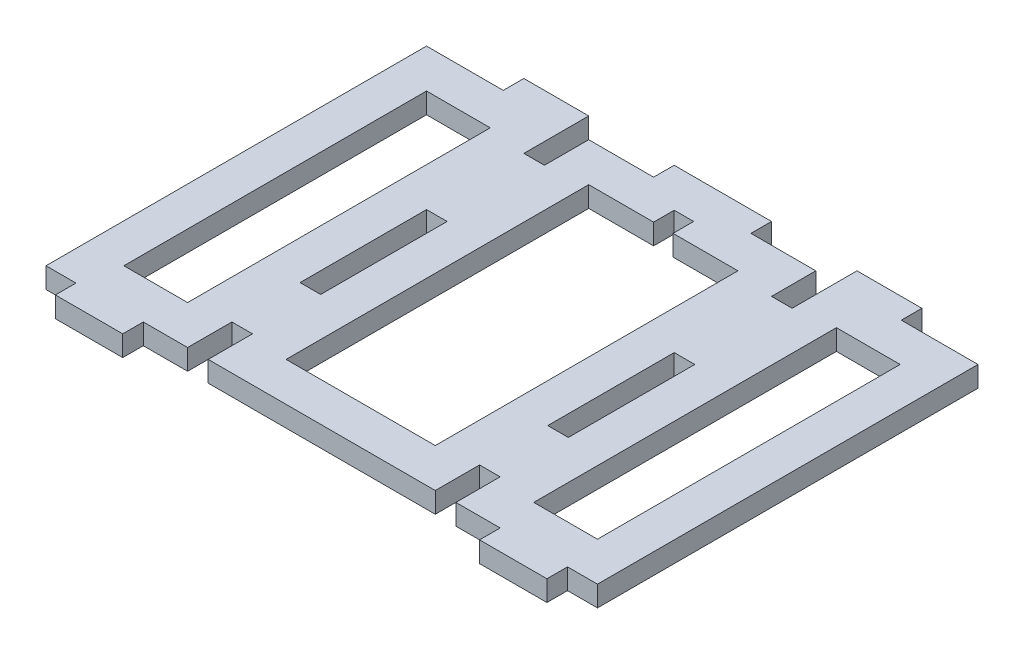
from build123d import *

# Parameters (mm, degrees)
SKETCH1_W           = 85
SKETCH1_H           = 65
BOSS_EXTRUDE1_DEPTH = 3.175
SKETCH2_W           = 3.175
SKETCH2_H           = 6.825
SKETCH2_H_2         = 3.175
SKETCH2_W_2         = 6.825
SKETCH2_W_3         = 4.619
SKETCH2_W_4         = 35
SKETCH2_H_3         = 19.492
SKETCH2_W_5         = 11.825
SKETCH2_W_6         = 10
CUT_EXTRUDE1_DEPTH  = 4.175
CUT_EXTRUDE2_DEPTH  = 4.175


with BuildPart() as part:
    # Sketch1 → Boss-Extrude1 (new body)
    with BuildSketch(Plane(origin=(0, 0, 0), x_dir=(1, 0, 0), z_dir=(0, 1, 0))):
        with Locations((42.5, 32.5)):
            Rectangle(SKETCH1_W, SKETCH1_H)
    extrude(amount=BOSS_EXTRUDE1_DEPTH)

    # Sketch2 → Cut-Extrude1 (cut, through all)
    with BuildSketch(Plane.XZ):
        with Locations((23.4125, -6.5875)):
            Rectangle(SKETCH2_W, SKETCH2_H)
        with Locations((23.4125, -1.5875)):
            Rectangle(SKETCH2_W, SKETCH2_H_2)
        with Locations((18.4125, -1.5875)):
            Rectangle(SKETCH2_W_2, SKETCH2_H_2)
        with Locations((2.3095, -1.5875)):
            Rectangle(SKETCH2_W_3, SKETCH2_H_2)
        with Locations((66.5875, -1.5875)):
            Rectangle(SKETCH2_W_2, SKETCH2_H_2)
        with Locations((61.5875, -1.5875)):
            Rectangle(SKETCH2_W, SKETCH2_H_2)
        with Locations((82.6905, -1.5875)):
            Rectangle(SKETCH2_W_3, SKETCH2_H_2)
        with Locations((42.5, -1.5875)):
            Rectangle(SKETCH2_W_4, SKETCH2_H_2)
        with Locations((61.5875, -6.5875)):
            Rectangle(SKETCH2_W, SKETCH2_H)
        with Locations((61.5875, -30.254)):
            Rectangle(SKETCH2_W, SKETCH2_H_3)
        with Locations((23.4125, -30.254)):
            Rectangle(SKETCH2_W, SKETCH2_H_3)
        Polygon((21.825, -65), (25, -65), (25, -61.825), (25, -55), (21.825, -55), align=None)
        Polygon((60, -65), (63.175, -65), (63.175, -55), (60, -55), (60, -61.825), align=None)
        with Locations((79.0875, -63.4125)):
            Rectangle(SKETCH2_W_5, SKETCH2_H_2)
        with Locations((55, -63.4125)):
            Rectangle(SKETCH2_W_6, SKETCH2_H_2)
        with Locations((30, -63.4125)):
            Rectangle(SKETCH2_W_6, SKETCH2_H_2)
        with Locations((5.9125, -63.4125)):
            Rectangle(SKETCH2_W_5, SKETCH2_H_2)
    extrude(amount=-CUT_EXTRUDE1_DEPTH, mode=Mode.SUBTRACT)

    # Sketch3 → Cut-Extrude2 (cut, through all)
    with BuildSketch(Plane(origin=(0, 3.175, 0), x_dir=(1, 0, 0), z_dir=(0, 1, 0))):
        Polygon((69.175, 49), (69.175, 16), (69.175, 9.175), (79, 9.175), (79, 55.825), (69.175, 55.825), align=None)
        Polygon((31, 55.825), (31, 9.175), (54, 9.175), (54, 55.825), (44, 55.825), (44, 59), (41, 59), (41, 55.825), align=None)
        Polygon((15.825, 49), (15.825, 55.825), (6, 55.825), (6, 9.175), (15.825, 9.175), (15.825, 16), align=None)
    extrude(amount=-CUT_EXTRUDE2_DEPTH, mode=Mode.SUBTRACT)


solid = part.part
